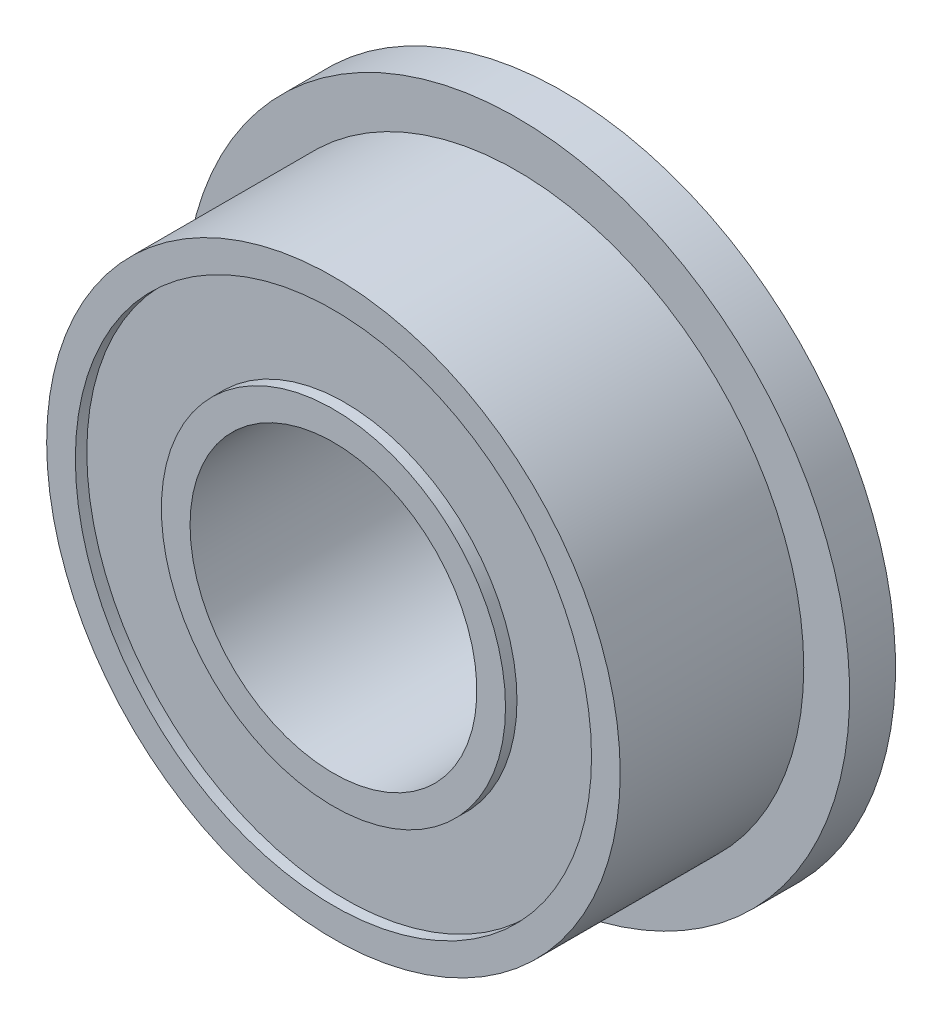
from build123d import *

# Parameters (mm, degrees)
SKETCH_1_R          = 5
EXTRUDE_1_DEPTH     = 4
SKETCH_2_R          = 5.8
EXTRUDE_2_DEPTH     = 0.8
SKETCH_3_R          = 2.5
CUT_EXTRUDE_1_DEPTH = 5
SKETCH_4_R          = 5.1
SKETCH_4_R_2        = 3.3
CUT_EXTRUDE_3_DEPTH = 0.2
SKETCH_5_R          = 4.5
SKETCH_5_R_2        = 3
CUT_EXTRUDE_4_DEPTH = 0.2


with BuildPart() as part:
    # 草圖1 → 填料-伸長1 (new body)
    with BuildSketch(Plane.XY):
        Circle(SKETCH_1_R)
    extrude(amount=EXTRUDE_1_DEPTH)

    # 草圖2 → 填料-伸長2 (add)
    with BuildSketch(Plane(origin=(0, 0, 0), x_dir=(-1, 0, 0), z_dir=(0, 0, -1))):
        Circle(SKETCH_2_R)
    extrude(amount=-EXTRUDE_2_DEPTH)

    # 草圖3 → 除料-伸長1 (cut, through all)
    with BuildSketch(Plane(origin=(0, 0, 0), x_dir=(-1, 0, 0), z_dir=(0, 0, -1))):
        Circle(SKETCH_3_R)
    extrude(amount=-CUT_EXTRUDE_1_DEPTH, mode=Mode.SUBTRACT)

    # 草圖4 → 除料-伸長3 (cut)
    with BuildSketch(Plane(origin=(0, 0, 0), x_dir=(-1, 0, 0), z_dir=(0, 0, -1))):
        Circle(SKETCH_4_R)
        Circle(SKETCH_4_R_2, mode=Mode.SUBTRACT)
    extrude(amount=-CUT_EXTRUDE_3_DEPTH, mode=Mode.SUBTRACT)

    # 草圖5 → 除料-伸長4 (cut)
    with BuildSketch(Plane.XY.offset(4)):
        Circle(SKETCH_5_R)
        Circle(SKETCH_5_R_2, mode=Mode.SUBTRACT)
    extrude(amount=-CUT_EXTRUDE_4_DEPTH, mode=Mode.SUBTRACT)


solid = part.part
